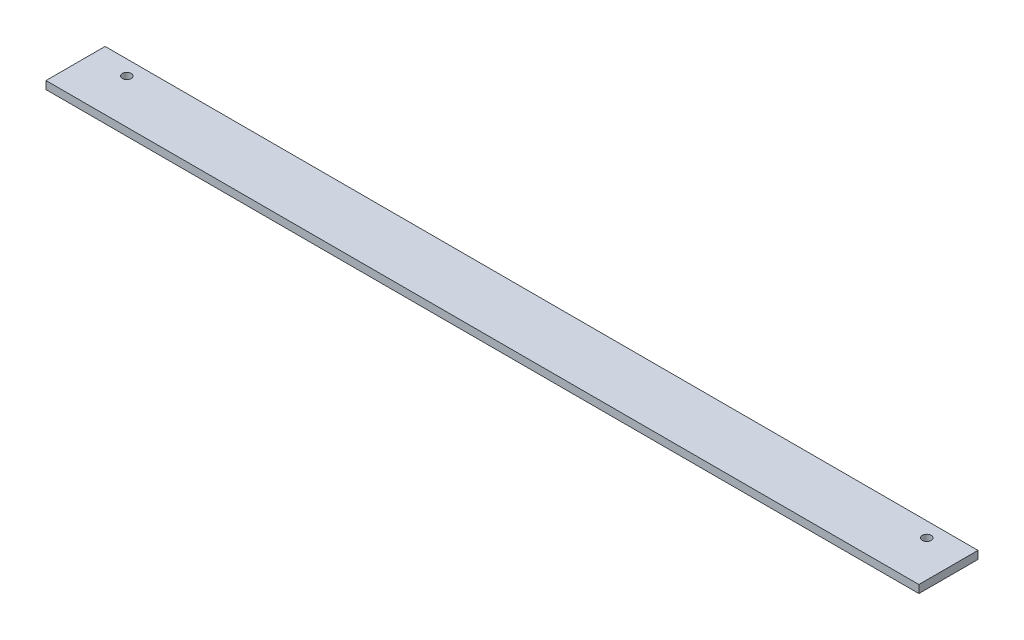
from build123d import *

# Parameters (mm, degrees)
SKETCH_1_W          = 30
SKETCH_1_H          = 4
EXTRUDE_1_DEPTH     = 443
SKETCH_2_R          = 2.25
CUT_EXTRUDE_1_DEPTH = 5


with BuildPart() as part:
    # Эскиз1 → Бобышка-Вытянуть1 (new body)
    with BuildSketch(Plane(origin=(0, 0, 0), x_dir=(0, 0, -1), z_dir=(1, 0, 0))):
        Rectangle(SKETCH_1_W, SKETCH_1_H)
    extrude(amount=EXTRUDE_1_DEPTH)

    # Эскиз2 → Вырез-Вытянуть1 (cut, through all)
    with BuildSketch(Plane(origin=(0, 2, 0), x_dir=(1, 0, 0), z_dir=(0, 1, 0))):
        with Locations((18.5, 7.5)):
            Circle(SKETCH_2_R)
        with Locations((424.5, 7.5)):
            Circle(SKETCH_2_R)
    extrude(amount=-CUT_EXTRUDE_1_DEPTH, mode=Mode.SUBTRACT)


solid = part.part
